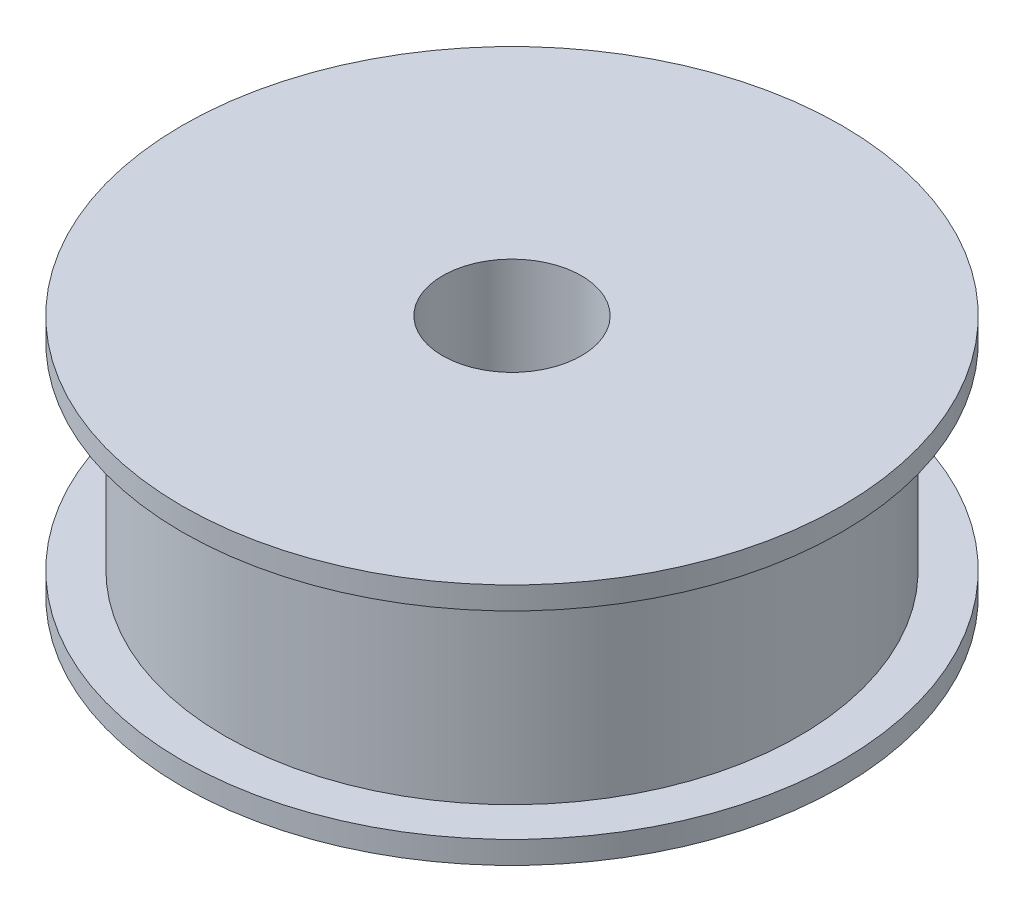
from build123d import *


with BuildPart() as part:
    # Sketch1 → Revolve1 (revolve)
    with BuildSketch(Plane(origin=(0, 0, 0), x_dir=(0, 0, -1), z_dir=(1, 0, 0))):
        Polygon((-4, -7), (-4, 7), (-19, 7), (-19, 5.7), (-16.55, 5.7), (-16.55, -5.7), (-19, -5.7), (-19, -7), align=None)
    revolve(axis=Axis((0, 7.7, 0), (0, -1, 0)))


solid = part.part
